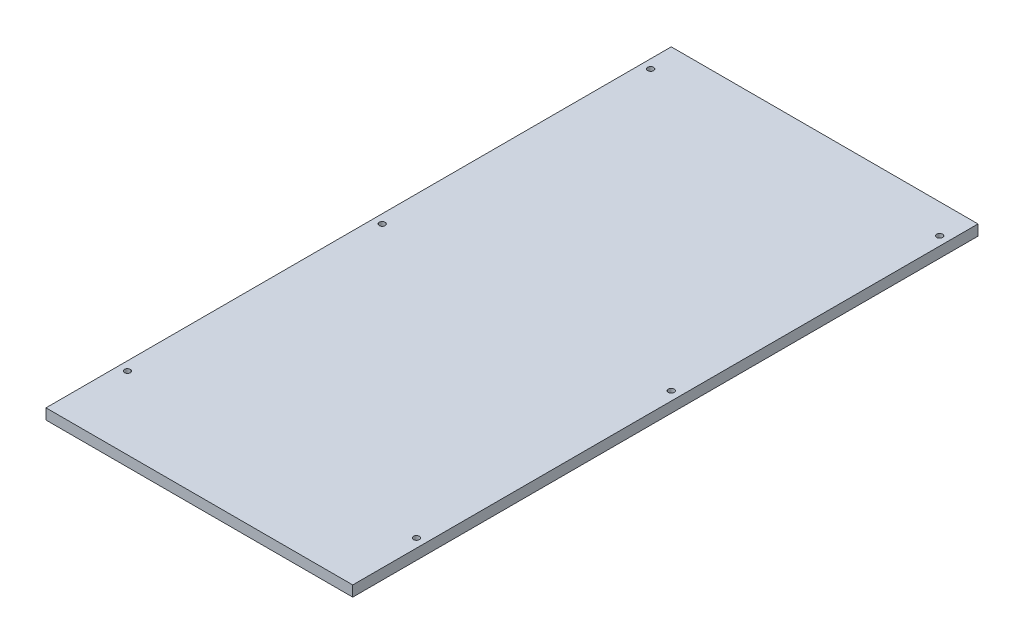
from build123d import *

# Parameters (mm, degrees)
SKETCH1_W           = 520
SKETCH1_H           = 1060
BOSS_EXTRUDE1_DEPTH = 18
SKETCH2_R           = 5
CUT_EXTRUDE1_DEPTH  = 19


with BuildPart() as part:
    # Sketch1 → Boss-Extrude1 (new body)
    with BuildSketch(Plane(origin=(0, 0, 0), x_dir=(1, 0, 0), z_dir=(0, 1, 0))):
        with Locations((0, -530)):
            Rectangle(SKETCH1_W, SKETCH1_H)
    extrude(amount=BOSS_EXTRUDE1_DEPTH)

    # Sketch2 → Cut-Extrude1 (cut, through all)
    with BuildSketch(Plane(origin=(0, 18, 0), x_dir=(1, 0, 0), z_dir=(0, 1, 0))):
        with Locations((245, -50)):
            Circle(SKETCH2_R)
        with Locations((-245, -50)):
            Circle(SKETCH2_R)
        with Locations((245, -505)):
            Circle(SKETCH2_R)
        with Locations((245, -937)):
            Circle(SKETCH2_R)
        with Locations((-245, -937)):
            Circle(SKETCH2_R)
        with Locations((-245, -505)):
            Circle(SKETCH2_R)
    extrude(amount=-CUT_EXTRUDE1_DEPTH, mode=Mode.SUBTRACT)


solid = part.part
